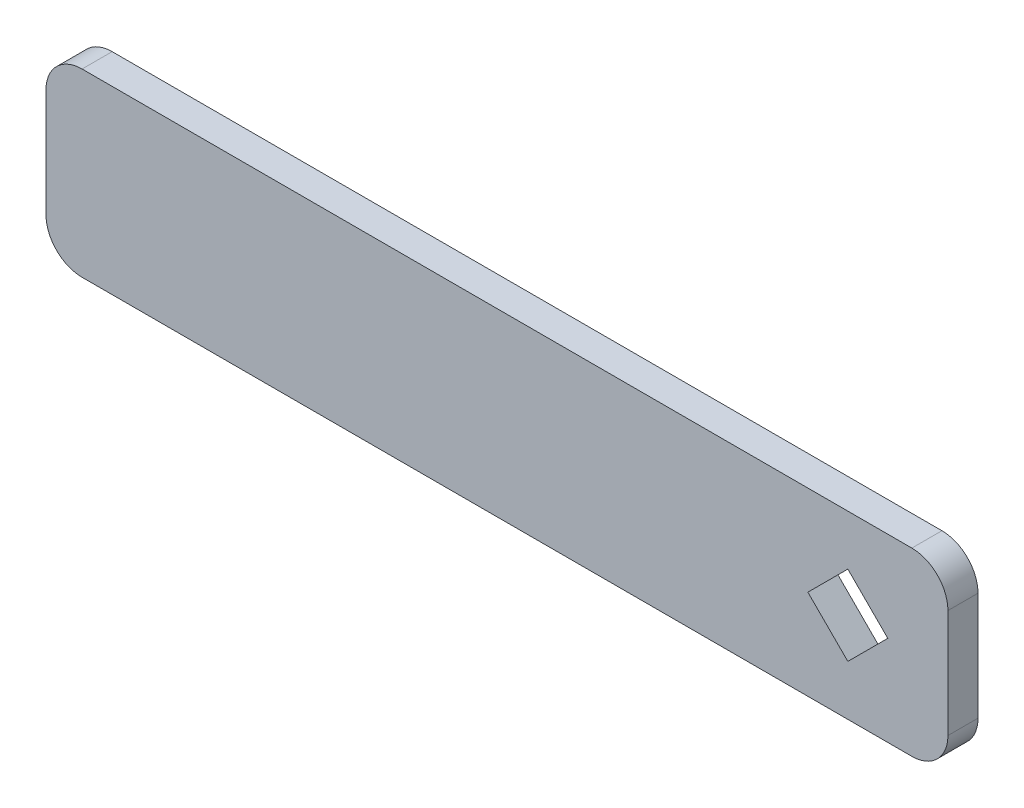
from build123d import *

# Parameters (mm, degrees)
ESQUISSE1_W        = 150
ESQUISSE1_H        = 30
BOSS_EXTRU_1_DEPTH = 5
CONG_1_R           = 6


with BuildPart() as part:
    # Esquisse1 → Boss.-Extru.1 (new body)
    with BuildSketch(Plane.XY):
        Rectangle(ESQUISSE1_W, ESQUISSE1_H)
        Polygon((58.353196257, -6.646803743), (51.706392514, 0), (58.353196257, 6.646803743), (65, 0), align=None, mode=Mode.SUBTRACT)
    extrude(amount=BOSS_EXTRU_1_DEPTH)

    # Congé1
    cong_1_edges = [part.edges().sort_by_distance(p)[0] for p in [
        (75, -15, 2.5),
        (-75, -15, 2.5),
        (-75, 15, 2.5),
        (75, 15, 2.5),
    ]]
    fillet(cong_1_edges, radius=CONG_1_R)


solid = part.part
